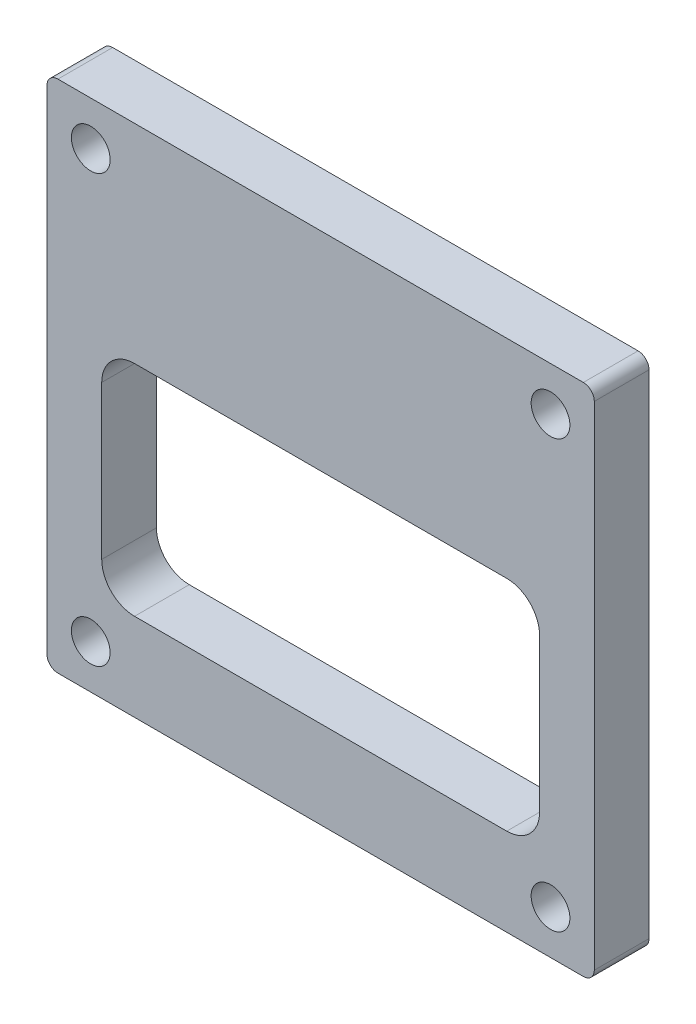
from build123d import *

# Parameters (mm, degrees)
SKETCH1_W             = 63.5
SKETCH1_H             = 59.69
BOSS_EXTRUDE1_DEPTH   = 6.35
FILLET1_R             = 1.27
F_8_CLEARANCE_HOLE1_D = 4.4958
SKETCH7_W             = 50.8
SKETCH7_H             = 25.4
CUT_EXTRUDE1_DEPTH    = 7.35
FILLET2_R             = 3.81


with BuildPart() as part:
    # Sketch1 → Boss-Extrude1 (new body)
    with BuildSketch(Plane.XY):
        with Locations((31.75, 29.845)):
            Rectangle(SKETCH1_W, SKETCH1_H)
    extrude(amount=BOSS_EXTRUDE1_DEPTH)

    # Fillet1
    fillet1_edges = [part.edges().sort_by_distance(p)[0] for p in [
        (0, 59.69, 3.175),
        (63.5, 59.69, 3.175),
        (63.5, 0, 3.175),
        (0, 0, 3.175),
    ]]
    fillet(fillet1_edges, radius=FILLET1_R)

    # #8 Clearance Hole1 (through all)
    with Locations(Plane.XY.offset(6.35)):
        with Locations((5.08, 54.61), (58.42, 54.61), (58.42, 5.08), (5.08, 5.08)):
            Hole(F_8_CLEARANCE_HOLE1_D / 2)

    # Sketch7 → Cut-Extrude1 (cut, through all)
    with BuildSketch(Plane.XY.offset(6.35)):
        with Locations((31.75, 22.86)):
            Rectangle(SKETCH7_W, SKETCH7_H)
    extrude(amount=-CUT_EXTRUDE1_DEPTH, mode=Mode.SUBTRACT)

    # Fillet2
    fillet2_edges = [part.edges().sort_by_distance(p)[0] for p in [
        (6.35, 10.16, 3.175),
        (6.35, 35.56, 3.175),
        (57.15, 35.56, 3.175),
        (57.15, 10.16, 3.175),
    ]]
    fillet(fillet2_edges, radius=FILLET2_R)


solid = part.part
